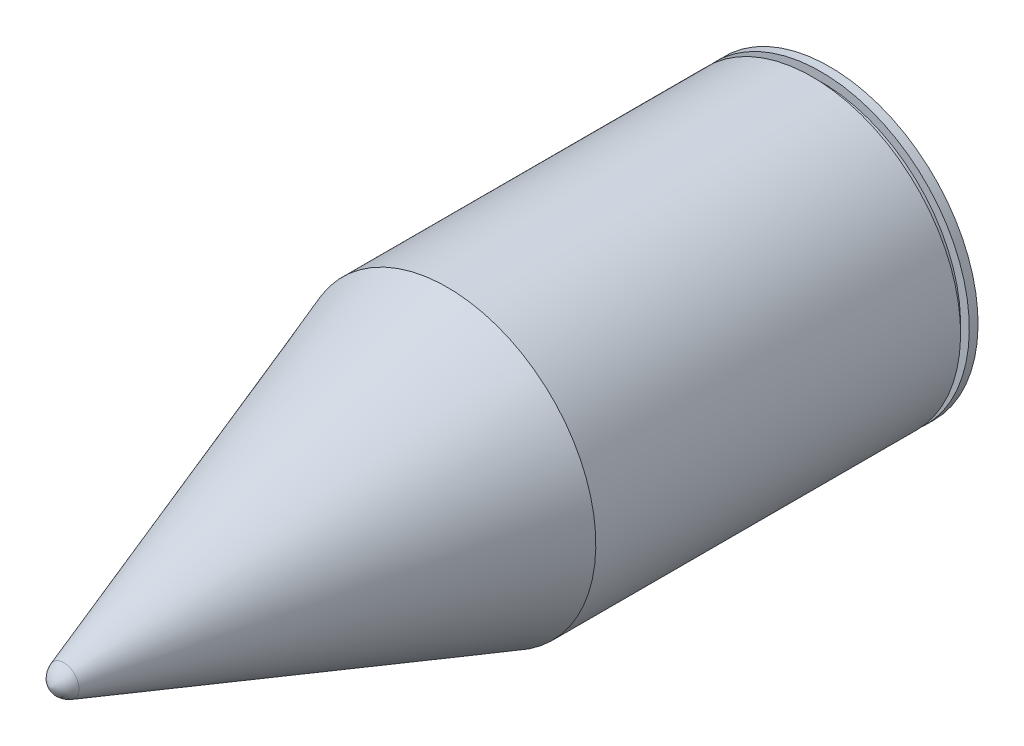
from build123d import *


with BuildPart() as part:
    # Sketch2 → Revolve1 (revolve)
    with BuildSketch(Plane(origin=(0, 0, 0), x_dir=(0, 0, -1), z_dir=(1, 0, 0))):
        with BuildLine():
            Line((872, 170), (872, 160))
            Line((872, 160), (882, 160))
            Line((882, 160), (882, 170))
            Line((882, 170), (892, 170))
            Line((892, 170), (892, 155))
            Line((892, 155), (902, 155))
            Line((902, 155), (902, 0))
            Line((902, 0), (0, 0))
            ThreePointArc((0, 0), (5.070327573, 10.637295113), (14.806941198, 17.274962183))
            Line((14.806941198, 17.274962183), (454.182547616, 170))
            Line((454.182547616, 170), (872, 170))
        make_face()
    revolve(axis=Axis((0, 0, 0), (0, 0, -1)))


solid = part.part
